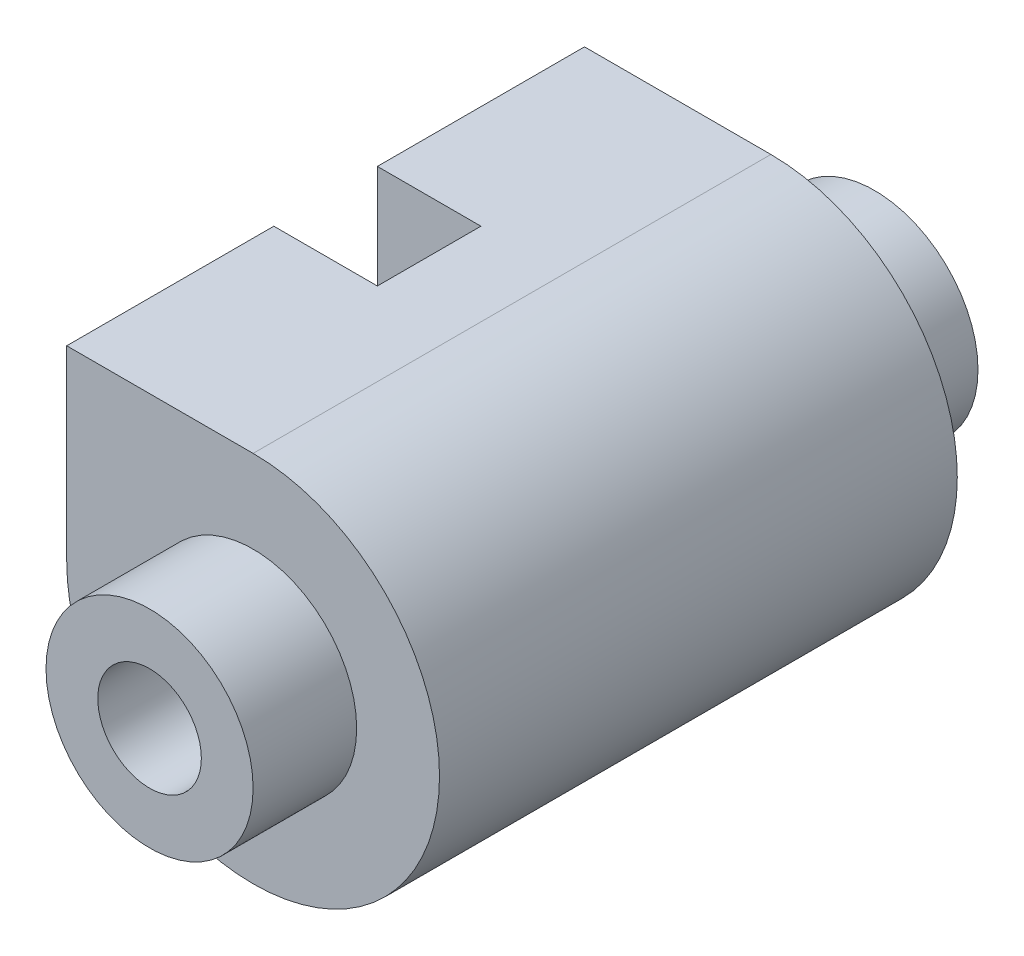
from build123d import *

# Parameters (mm, degrees)
SKETCH_1_R               = 3.6
EXTRUDE_1_DEPTH          = 10
SKETCH_2_R               = 2
SKETCH_2_R_2             = 1
EXTRUDE_2_DEPTH          = 2
SKETCH_4_R               = 2
EXTRUDE_3_DEPTH          = 2
SKETCH_5_R               = 1.8
EXTRUDE_4_DEPTH          = 3.6
SKETCH_2_3_R             = 1
CUT_EXTRUDE_2_DEPTH      = 3
CUT_EXTRUDE_2_DEPTH_BACK = 13
EXTRUDE_5_DEPTH          = 10
SKETCH_10_W              = 2
SKETCH_10_H              = 2


with BuildPart() as part:
    # Sketch 1 → Extrude 1 (new body)
    with BuildSketch(Plane.XY):
        Circle(SKETCH_1_R)
    extrude(amount=EXTRUDE_1_DEPTH)

    # Sketch 2 → Extrude 2 (add)
    with BuildSketch(Plane.XY.offset(10)):
        Circle(SKETCH_2_R)
        Circle(SKETCH_2_R_2, mode=Mode.SUBTRACT)
    extrude(amount=EXTRUDE_2_DEPTH)

    # Sketch 4 → Extrude 3 (add)
    with BuildSketch(Plane(origin=(0, 0, 0), x_dir=(-1, 0, 0), z_dir=(0, 0, -1))):
        with Locations(Location((0, 0, 0), (0, 0, 180))):  # turned: the seam where the file's is
            Circle(SKETCH_4_R)
    extrude(amount=EXTRUDE_3_DEPTH)

    # Sketch 5 → Extrude 4 (add)
    with BuildSketch(Plane(origin=(0, 0, 0), x_dir=(1, 0, 0), z_dir=(0, 1, 0))):
        with Locations((-1.8, -5)):
            Circle(SKETCH_5_R)
    extrude(amount=EXTRUDE_4_DEPTH)

    # Sketch 2_3 → Cut-Extrude 2 (cut, two sides)
    with BuildSketch(Plane.XY.offset(10)) as cut_extrude_2_sk:
        Circle(SKETCH_2_3_R)
    extrude(amount=CUT_EXTRUDE_2_DEPTH, mode=Mode.SUBTRACT)
    extrude(cut_extrude_2_sk.sketch, amount=-CUT_EXTRUDE_2_DEPTH_BACK, mode=Mode.SUBTRACT)

    # Sketch 8 → Extrude 5 (add)
    with BuildSketch(Plane.XY.offset(10)):
        Polygon((0, 3.6), (-3.6, 0), (-3.6, 3.6), align=None)
    extrude(amount=-EXTRUDE_5_DEPTH)

    # Sweep 1: sweep along a path in Sketch 11
    with BuildLine(Plane.XY.offset(5)) as sweep_1_path:
        Line((-2.6, 3.6), (-2.6, 1.5011107))
        Line((-2.6, 1.5011107), (0, 0))
    # Sketch 10 → Sweep 1 (sweep, cut)
    with BuildSketch(Plane(origin=(0, 3.6, 0), x_dir=(1, 0, 0), z_dir=(0, 1, 0))):
        with Locations((-2.6, -5)):
            Rectangle(SKETCH_10_W, SKETCH_10_H)
    sweep(path=sweep_1_path.line, transition=Transition.RIGHT, mode=Mode.SUBTRACT)


solid = part.part
